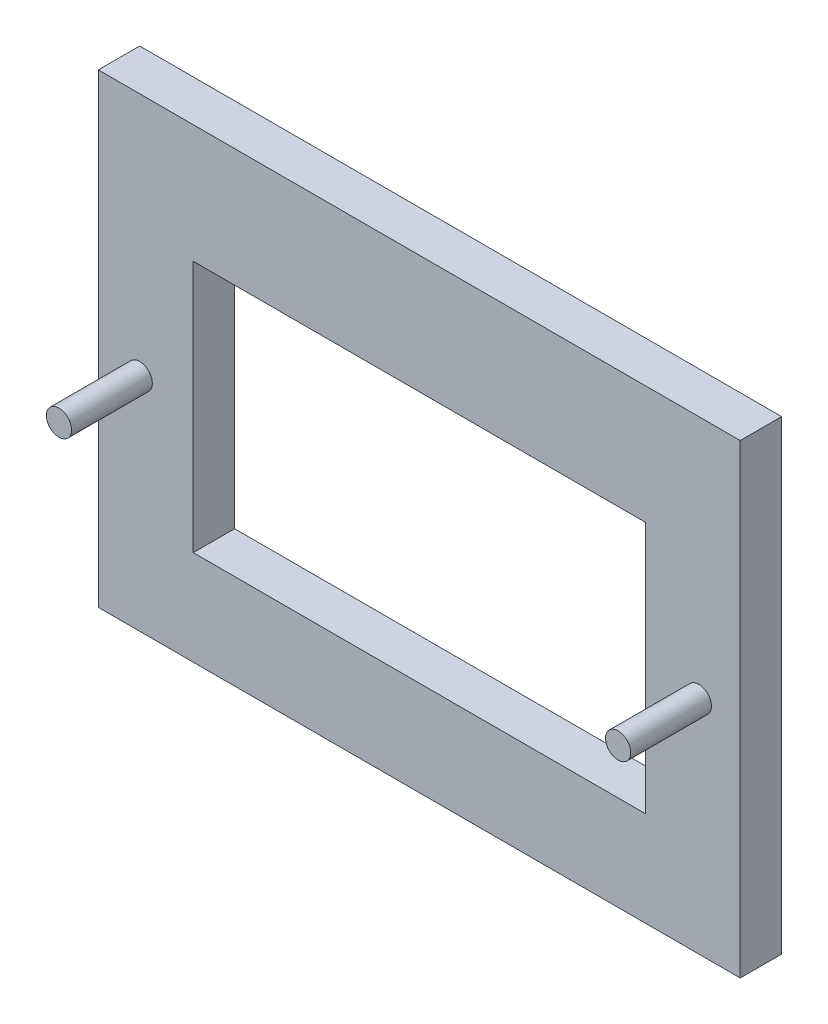
from build123d import *

# Parameters (mm, degrees)
SKETCH1_R             = 0.625
SKETCH1_W             = 22.4
SKETCH1_H             = 12.5
BOSS_EXTRUDE1_DEPTH   = 2.05
SKETCH4_R             = 0.625
BOSS_EXTRUDE2_DEPTH   = 4
BOSS_EXTRUDE2_2_DEPTH = 4


with BuildPart() as part:
    # Sketch1 → Boss-Extrude1 (new body)
    with BuildSketch(Plane.XY):
        Polygon((0, 0), (31.8, 0), (31.8, 21.9), (31.8, 23.06), (0, 23.06), (0, 21.9), align=None)
        with Locations((29.75, 10.95)):
            Circle(SKETCH1_R, mode=Mode.SUBTRACT)
        with Locations((2.05, 10.95)):
            Circle(SKETCH1_R, mode=Mode.SUBTRACT)
        with Locations((15.9, 10.95)):
            Rectangle(SKETCH1_W, SKETCH1_H, mode=Mode.SUBTRACT)
    extrude(amount=BOSS_EXTRUDE1_DEPTH)


with BuildPart() as body_2:
    # Sketch4 → Boss-Extrude2 (new body)
    with BuildSketch(Plane.XY.offset(2.05)):
        with Locations((2.05, 10.95)):
            Circle(SKETCH4_R)
    extrude(amount=BOSS_EXTRUDE2_DEPTH)


with BuildPart() as body_3:
    # Sketch4 → Boss-Extrude2 2 (new body)
    with BuildSketch(Plane.XY.offset(2.05)):
        with Locations((29.75, 10.95)):
            Circle(SKETCH4_R)
    extrude(amount=BOSS_EXTRUDE2_2_DEPTH)


solid = Compound([part.part, body_2.part, body_3.part])
